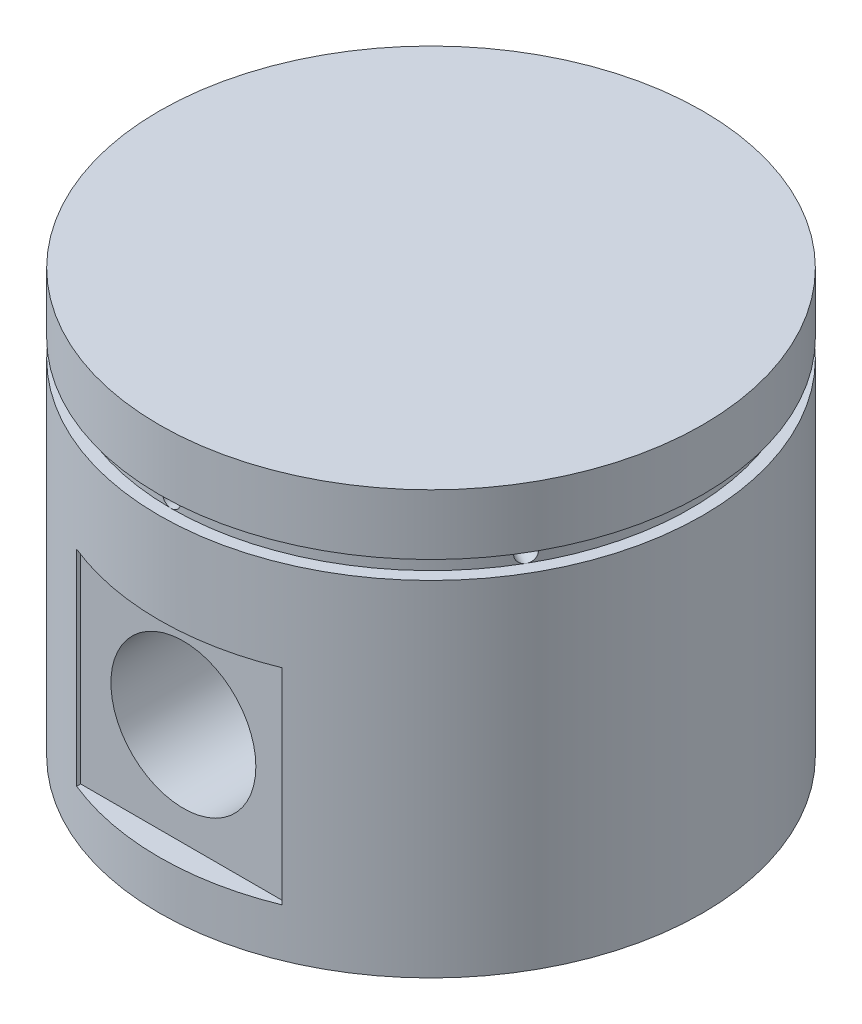
from build123d import *

# Parameters (mm, degrees)
IZIM1_R                     = 45
Y_KSEKLIK_EKSTR_ZYON1_DEPTH = 35
IZIM2_W                     = 34
IZIM2_H                     = 34
KES_EKSTR_ZYON1_DEPTH       = 4
IZIM5_R                     = 12
KES_EKSTR_ZYON2_DEPTH       = 107.536378763
KES_EKSTR_ZYON3_DEPTH       = 19
IZIM8_R                     = 45
IZIM8_R_2                   = 43
KES_EKSTR_ZYON4_DEPTH       = 1.5
KES_EKSTR_ZYON5_REACH       = 108.536
IZIM9_R                     = 1.5
DAIRESEL_KAPLAMA1_COUNT     = 6


with BuildPart() as part:
    # Çizim1 → Yükseklik-Ekstrüzyon1 (new, symmetric)
    with BuildSketch(Plane(origin=(0, 0, 0), x_dir=(1, 0, 0), z_dir=(0, 1, 0))):
        with Locations(Location((0, 0, 0), (0, 0, 270))):
            Circle(IZIM1_R)
    extrude(amount=Y_KSEKLIK_EKSTR_ZYON1_DEPTH, both=True)

    # Çizim2 → Kes-Ekstrüzyon1 (cut)
    with BuildSketch(Plane.XY.offset(45)):
        with Locations((0, -10)):
            Rectangle(IZIM2_W, IZIM2_H)
    kes_ekstr_zyon1 = extrude(amount=-KES_EKSTR_ZYON1_DEPTH, mode=Mode.SUBTRACT)

    # Aynalama1: Kes-Ekstrüzyon1 across plane
    add(kes_ekstr_zyon1.mirror(Plane.XY), mode=Mode.SUBTRACT)

    # Çizim5 → Kes-Ekstrüzyon2 (cut, through all)
    with BuildSketch(Plane.XY.offset(45)):
        with Locations((0, -10)):
            Circle(IZIM5_R)
    extrude(amount=-KES_EKSTR_ZYON2_DEPTH, mode=Mode.SUBTRACT)

    # Çizim7 → Kes-Ekstrüzyon3 (cut, symmetric)
    with BuildSketch(Plane(origin=(0, 0, 0), x_dir=(0, 0, -1), z_dir=(1, 0, 0))):
        with BuildLine():
            Line((38, -35), (38, -27))
            Line((38, -27), (12, -27))
            Line((12, -27), (12, 11))
            Line((12, 11), (38, 11))
            Line((38, 11), (38, 26))
            ThreePointArc((38, 26), (37.414213562, 27.414213562), (36, 28))
            Line((36, 28), (-36, 28))
            ThreePointArc((-36, 28), (-37.414213562, 27.414213562), (-38, 26))
            Line((-38, 26), (-38, 11))
            Line((-38, 11), (-11.999999881, 11))
            Line((-11.999999881, 11), (-11.999999881, -27))
            Line((-11.999999881, -27), (-38, -27))
            Line((-38, -27), (-38, -35))
            Line((-38, -35), (38, -35))
        make_face()
    extrude(amount=KES_EKSTR_ZYON3_DEPTH, both=True, mode=Mode.SUBTRACT)

    # Çizim8 → Kes-Ekstrüzyon4 (cut, symmetric)
    with BuildSketch(Plane(origin=(0, 23.5, 0), x_dir=(1, 0, 0), z_dir=(0, 1, 0))):
        with Locations(Location((0, 0, 0), (0, 0, 270))):
            Circle(IZIM8_R)
        with Locations(Location((0, 0, 0), (0, 0, 270))):
            Circle(IZIM8_R_2, mode=Mode.SUBTRACT)
    extrude(amount=KES_EKSTR_ZYON4_DEPTH, both=True, mode=Mode.SUBTRACT)

    # Çizim9 → Kes-Ekstrüzyon5 (cut, up to next)
    with BuildSketch(Plane.XY.offset(45), mode=Mode.PRIVATE) as kes_ekstr_zyon5_sk1:
        with Locations(Location((0, 23.5, 0), (0, 0, 90))):
            Circle(IZIM9_R)
    kes_ekstr_zyon5_tool1 = extrude(kes_ekstr_zyon5_sk1.sketch, amount=-KES_EKSTR_ZYON5_REACH, mode=Mode.PRIVATE) & part.part
    kes_ekstr_zyon5 = kes_ekstr_zyon5_tool1.solids().sort_by_distance((0, 23.5, 45))[0]
    add(kes_ekstr_zyon5, mode=Mode.SUBTRACT)

    # Dairesel Kaplama1: Kes-Ekstrüzyon5; each copy of Kes-Ekstrüzyon5 runs up to whatever stops it at its own place
    dairesel_kaplama1_before = part.part  # the part as the pattern finds it: every copy runs up to it
    dairesel_kaplama1_kes_ekstr_zyon5_long = extrude(kes_ekstr_zyon5_sk1.sketch, amount=-KES_EKSTR_ZYON5_REACH, mode=Mode.PRIVATE)
    dairesel_kaplama1_kes_ekstr_zyon5_tool = dairesel_kaplama1_kes_ekstr_zyon5_long.rotate(Axis((0, 25, 0), (0, 1, 0)), 1 * 360 / DAIRESEL_KAPLAMA1_COUNT) & dairesel_kaplama1_before
    add(dairesel_kaplama1_kes_ekstr_zyon5_tool.solids().sort_by_distance((38.971143, 23.5, 22.5))[0], mode=Mode.SUBTRACT)
    dairesel_kaplama1_kes_ekstr_zyon5_tool = dairesel_kaplama1_kes_ekstr_zyon5_long.rotate(Axis((0, 25, 0), (0, 1, 0)), 2 * 360 / DAIRESEL_KAPLAMA1_COUNT) & dairesel_kaplama1_before
    add(dairesel_kaplama1_kes_ekstr_zyon5_tool.solids().sort_by_distance((38.971143, 23.5, -22.5))[0], mode=Mode.SUBTRACT)
    dairesel_kaplama1_kes_ekstr_zyon5_tool = dairesel_kaplama1_kes_ekstr_zyon5_long.rotate(Axis((0, 25, 0), (0, 1, 0)), 3 * 360 / DAIRESEL_KAPLAMA1_COUNT) & dairesel_kaplama1_before
    add(dairesel_kaplama1_kes_ekstr_zyon5_tool.solids().sort_by_distance((0, 23.5, -45))[0], mode=Mode.SUBTRACT)
    dairesel_kaplama1_kes_ekstr_zyon5_tool = dairesel_kaplama1_kes_ekstr_zyon5_long.rotate(Axis((0, 25, 0), (0, 1, 0)), 4 * 360 / DAIRESEL_KAPLAMA1_COUNT) & dairesel_kaplama1_before
    add(dairesel_kaplama1_kes_ekstr_zyon5_tool.solids().sort_by_distance((-38.971143, 23.5, -22.5))[0], mode=Mode.SUBTRACT)
    dairesel_kaplama1_kes_ekstr_zyon5_tool = dairesel_kaplama1_kes_ekstr_zyon5_long.rotate(Axis((0, 25, 0), (0, 1, 0)), 5 * 360 / DAIRESEL_KAPLAMA1_COUNT) & dairesel_kaplama1_before
    add(dairesel_kaplama1_kes_ekstr_zyon5_tool.solids().sort_by_distance((-38.971143, 23.5, 22.5))[0], mode=Mode.SUBTRACT)


solid = part.part
